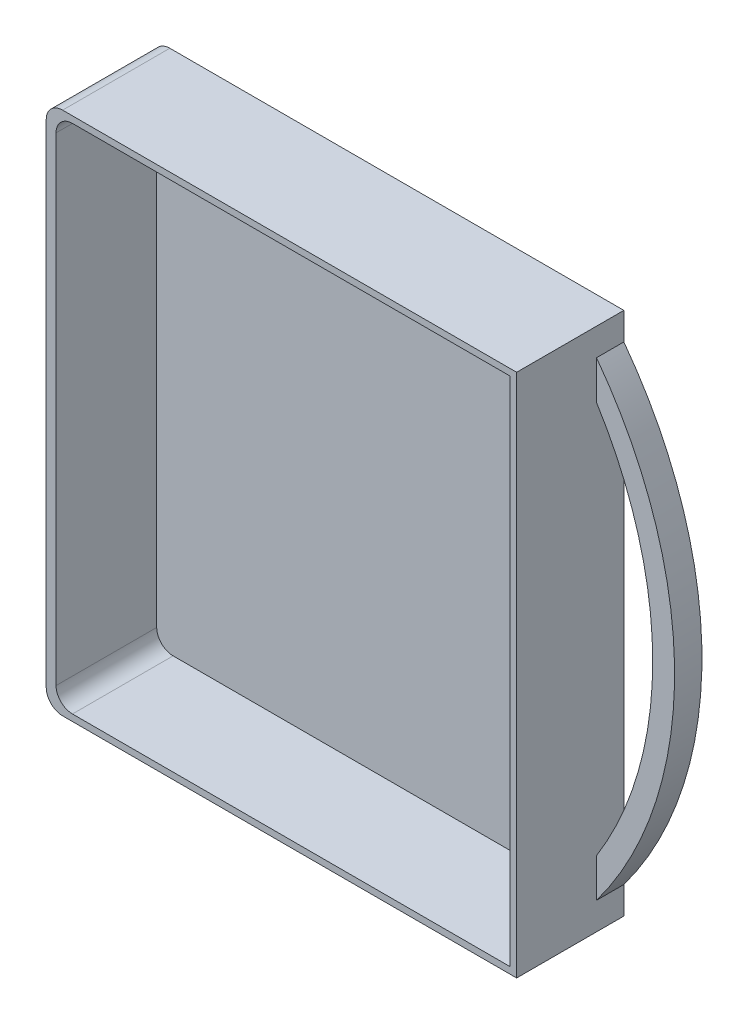
from build123d import *

# Parameters (mm, degrees)
SKETCH_1_W          = 86
SKETCH_1_H          = 95.9
EXTRUDE_1_DEPTH     = 19.6
EXTRUDE_2_DEPTH     = 5
SKETCH_3_W          = 83
SKETCH_3_H          = 93.5
CUT_EXTRUDE_1_DEPTH = 18.4
FILLET_1_R          = 3


with BuildPart() as part:
    # Эскиз1 → Бобышка-Вытянуть1 (new body)
    with BuildSketch(Plane.XY):
        Rectangle(SKETCH_1_W, SKETCH_1_H)
    extrude(amount=EXTRUDE_1_DEPTH)

    # Эскиз2 → Бобышка-Вытянуть2 (add)
    with BuildSketch(Plane(origin=(0, 0, 0), x_dir=(-1, 0, 0), z_dir=(0, 0, -1))):
        with BuildLine():
            Line((-43, 35.870635623), (-43, 42.95))
            ThreePointArc((-43, 42.95), (-57.275135929, 0), (-43, -42.95))
            Line((-43, -42.95), (-43, -35.870635623))
            ThreePointArc((-43, -35.870635623), (-53.275135929, 0), (-43, 35.870635623))
        make_face()
    extrude(amount=-EXTRUDE_2_DEPTH)

    # Эскиз3 → Вырез-Вытянуть1 (cut)
    with BuildSketch(Plane.XY.offset(19.6)):
        with Locations((0.3, 0)):
            Rectangle(SKETCH_3_W, SKETCH_3_H)
    extrude(amount=-CUT_EXTRUDE_1_DEPTH, mode=Mode.SUBTRACT)

    # Скругление1
    fillet_1_edges = [part.edges().sort_by_distance(p)[0] for p in [
        (-41.2, -46.75, 10.4),
        (-41.2, 46.75, 10.4),
        (-43, -47.95, 9.8),
        (-43, 47.95, 9.8),
    ]]
    fillet(fillet_1_edges, radius=FILLET_1_R)


solid = part.part
